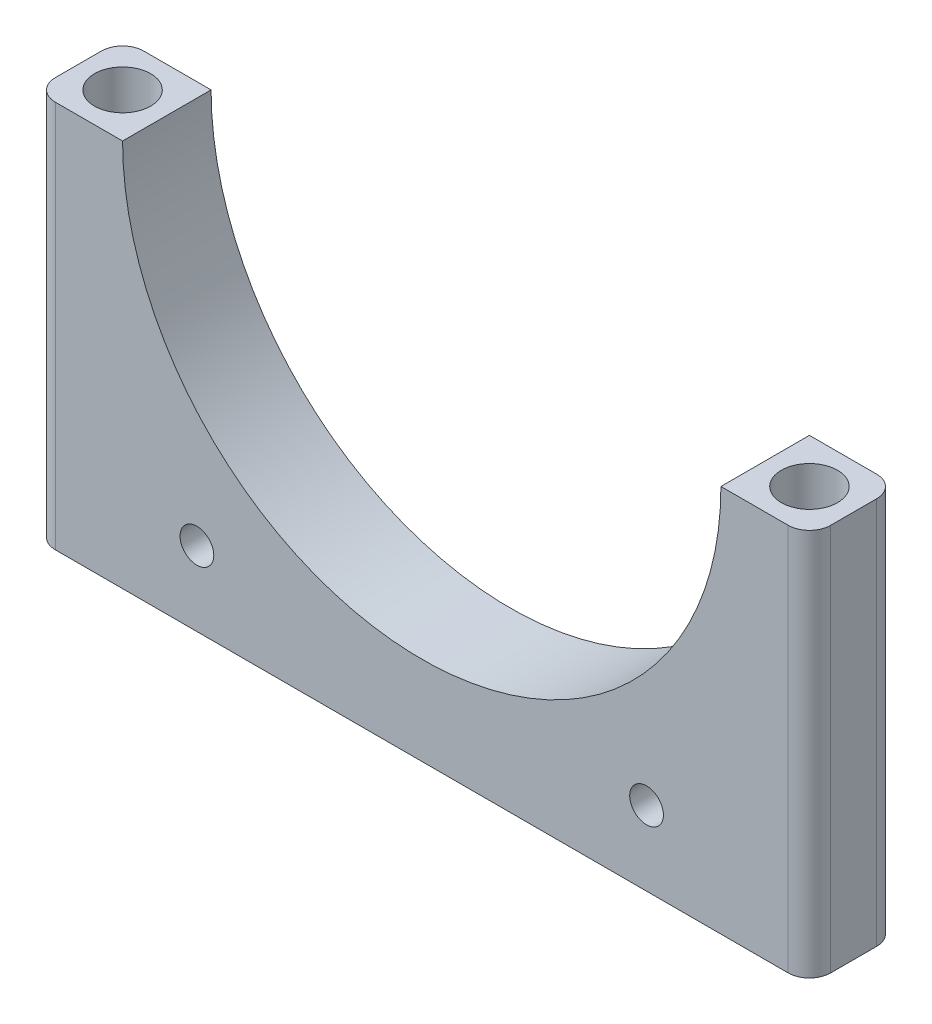
from build123d import *

# Parameters (mm, degrees)
BOSS_EXTRUDE1_DEPTH = 25
SKETCH5_R           = 7.94
CUT_EXTRUDE1_DEPTH  = 5000
SKETCH6_R           = 4.7625
CUT_EXTRUDE2_DEPTH  = 5000
FILLET2_R           = 6


with BuildPart() as part:
    # Sketch4 → Boss-Extrude1 (new body)
    with BuildSketch(Plane.XY):
        with BuildLine():
            ThreePointArc((0, -25), (-77.42819254, 7.07180746), (-109.5, 84.5))
            Line((-109.5, 84.5), (-109.5, -25))
            Line((-109.5, -25), (0, -25))
        make_face()
        with BuildLine():
            ThreePointArc((84.5, 84.5), (59.75052301, 24.74947699), (0, 0))
            ThreePointArc((0, 0), (-59.75052301, 24.74947699), (-84.5, 84.5))
            Line((-84.5, 84.5), (-109.5, 84.5))
            ThreePointArc((-109.5, 84.5), (-77.42819254, 7.07180746), (0, -25))
            ThreePointArc((0, -25), (77.42819254, 7.07180746), (109.5, 84.5))
            Line((109.5, 84.5), (84.5, 84.5))
        make_face()
        with BuildLine():
            Line((109.5, -25), (109.5, 84.5))
            ThreePointArc((109.5, 84.5), (77.42819254, 7.07180746), (0, -25))
            Line((0, -25), (109.5, -25))
        make_face()
    extrude(amount=BOSS_EXTRUDE1_DEPTH)

    # Sketch5 → Cut-Extrude1 (cut)
    with BuildSketch(Plane(origin=(0, 84.5, 0), x_dir=(1, 0, 0), z_dir=(0, 1, 0))):
        with Locations((-97, -12.5)):
            Circle(SKETCH5_R)
        with Locations((97, -12.5)):
            Circle(SKETCH5_R)
    extrude(amount=-CUT_EXTRUDE1_DEPTH, mode=Mode.SUBTRACT)

    # Sketch6 → Cut-Extrude2 (cut)
    with BuildSketch(Plane.XY.offset(25)):
        with Locations((-63.5, -4)):
            Circle(SKETCH6_R)
        with Locations((63.5, -4)):
            Circle(SKETCH6_R)
    extrude(amount=-CUT_EXTRUDE2_DEPTH, mode=Mode.SUBTRACT)

    # Fillet2
    fillet2_edges = [part.edges().sort_by_distance(p)[0] for p in [
        (109.5, 29.75, 25),
        (-109.5, 29.75, 25),
        (-109.5, 29.75, 0),
        (109.5, 29.75, 0),
    ]]
    fillet(fillet2_edges, radius=FILLET2_R)


solid = part.part
